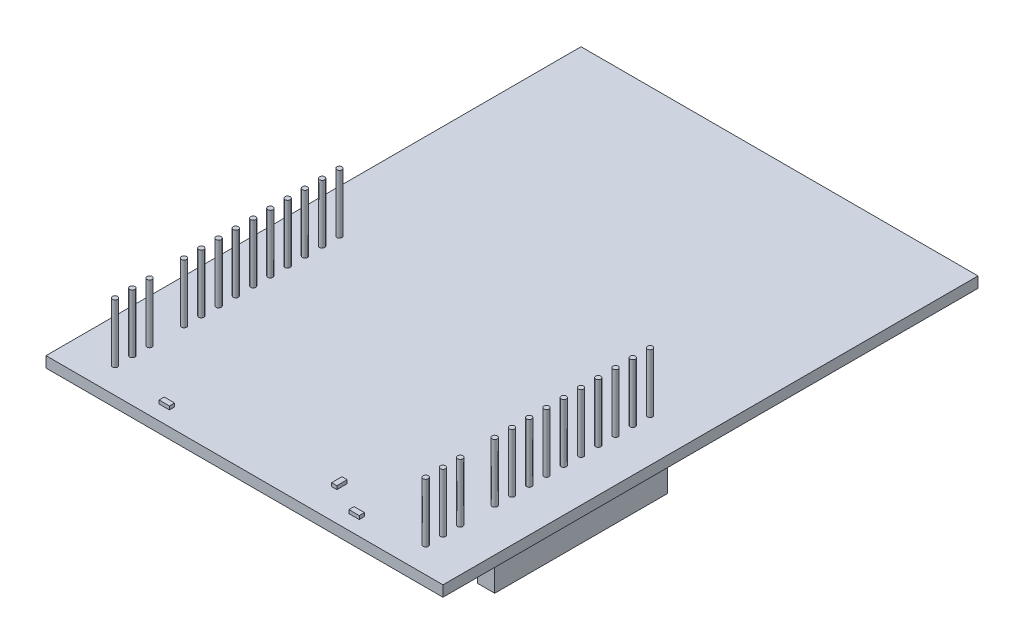
from build123d import *

# Parameters (mm, degrees)
SKETCH5_W           = 58.42
SKETCH5_H           = 78.74
BOSS_EXTRUDE1_DEPTH = 1.5875
SKETCH6_R           = 0.381
BOSS_EXTRUDE2_DEPTH = 8.636
SKETCH7_W           = 2.54
SKETCH7_H           = 25.4
BOSS_EXTRUDE3_DEPTH = 8.382
SKETCH8_W           = 1.524
SKETCH8_H           = 0.762
SKETCH8_W_2         = 0.762
SKETCH8_H_2         = 1.524
BOSS_EXTRUDE4_DEPTH = 0.508


with BuildPart() as part:
    # Sketch5 → Boss-Extrude1 (new body)
    with BuildSketch(Plane(origin=(0, 0, 0), x_dir=(1, 0, 0), z_dir=(0, 1, 0))):
        with Locations((0, 13.97)):
            Rectangle(SKETCH5_W, SKETCH5_H)
    extrude(amount=BOSS_EXTRUDE1_DEPTH)

    # Sketch6 → Boss-Extrude2 (add)
    with BuildSketch(Plane(origin=(0, 1.5875, 0), x_dir=(1, 0, 0), z_dir=(0, 1, 0))):
        with Locations((-22.86, -21.59)):
            Circle(SKETCH6_R)
        with Locations((22.86, -21.59)):
            Circle(SKETCH6_R)
        with Locations((-22.86, -19.05)):
            Circle(SKETCH6_R)
        with Locations((22.86, -19.05)):
            Circle(SKETCH6_R)
        with Locations((-22.86, -16.51)):
            Circle(SKETCH6_R)
        with Locations((22.86, -16.51)):
            Circle(SKETCH6_R)
        with Locations((-22.86, -11.43)):
            Circle(SKETCH6_R)
        with Locations((22.86, -11.43)):
            Circle(SKETCH6_R)
        with Locations((-22.86, -8.89)):
            Circle(SKETCH6_R)
        with Locations((22.86, -8.89)):
            Circle(SKETCH6_R)
        with Locations((-22.86, -6.35)):
            Circle(SKETCH6_R)
        with Locations((22.86, -6.35)):
            Circle(SKETCH6_R)
        with Locations((-22.86, -3.81)):
            Circle(SKETCH6_R)
        with Locations((22.86, -3.81)):
            Circle(SKETCH6_R)
        with Locations((-22.86, -1.27)):
            Circle(SKETCH6_R)
        with Locations((22.86, -1.27)):
            Circle(SKETCH6_R)
        with Locations((-22.86, 1.27)):
            Circle(SKETCH6_R)
        with Locations((22.86, 1.27)):
            Circle(SKETCH6_R)
        with Locations((-22.86, 3.81)):
            Circle(SKETCH6_R)
        with Locations((22.86, 3.81)):
            Circle(SKETCH6_R)
        with Locations((-22.86, 6.35)):
            Circle(SKETCH6_R)
        with Locations((22.86, 6.35)):
            Circle(SKETCH6_R)
        with Locations((-22.86, 8.89)):
            Circle(SKETCH6_R)
        with Locations((22.86, 8.89)):
            Circle(SKETCH6_R)
        with Locations((-22.86, 11.43)):
            Circle(SKETCH6_R)
        with Locations((22.86, 11.43)):
            Circle(SKETCH6_R)
    extrude(amount=BOSS_EXTRUDE2_DEPTH)

    # Sketch7 → Boss-Extrude3 (add)
    with BuildSketch(Plane.XZ):
        with Locations((-22.86, 0)):
            Rectangle(SKETCH7_W, SKETCH7_H)
        with Locations((22.86, 0)):
            Rectangle(SKETCH7_W, SKETCH7_H)
    extrude(amount=BOSS_EXTRUDE3_DEPTH)

    # Sketch8 → Boss-Extrude4 (add)
    with BuildSketch(Plane(origin=(0, 1.5875, 0), x_dir=(1, 0, 0), z_dir=(0, 1, 0))):
        with Locations((13.97, -22.86)):
            Rectangle(SKETCH8_W, SKETCH8_H)
        with Locations((8.89, -20.32)):
            Rectangle(SKETCH8_W_2, SKETCH8_H_2)
        with Locations((-13.97, -22.86)):
            Rectangle(SKETCH8_W, SKETCH8_H)
    extrude(amount=BOSS_EXTRUDE4_DEPTH)


solid = part.part
